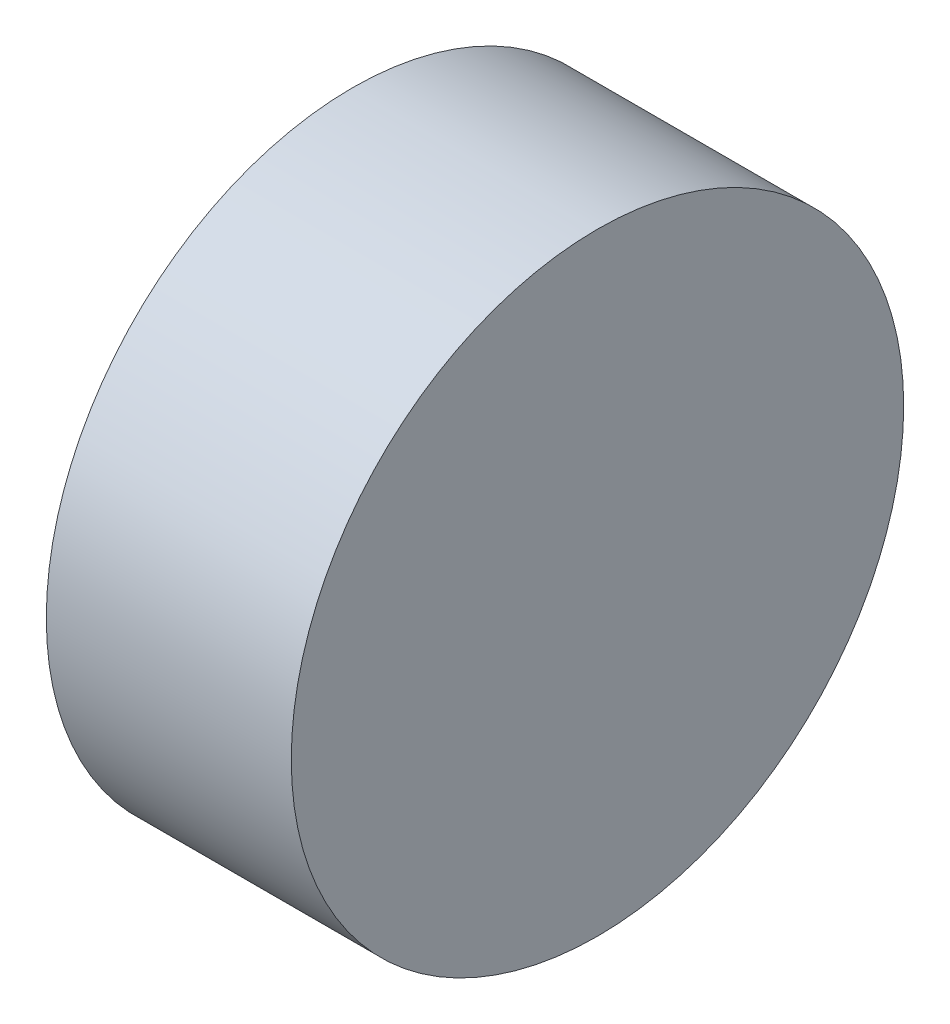
from build123d import *

# Parameters (mm, degrees)
SKETCH_1_W = 6
SKETCH_1_H = 7.5


with BuildPart() as part:
    # 草图1 → 旋转1 (revolve)
    with BuildSketch(Plane.XY, mode=Mode.PRIVATE) as revolve_1_sk:
        with Locations((133.06399853, 42.396589675)):
            Rectangle(SKETCH_1_W, SKETCH_1_H)
    revolve(revolve_1_sk.sketch.rotate(Axis((127.000400996, 38.646589675, 0), (1, 0, 0)), 90), axis=Axis((127.000400996, 38.646589675, 0), (1, 0, 0)))  # turned: the seam where the file's is


solid = part.part
